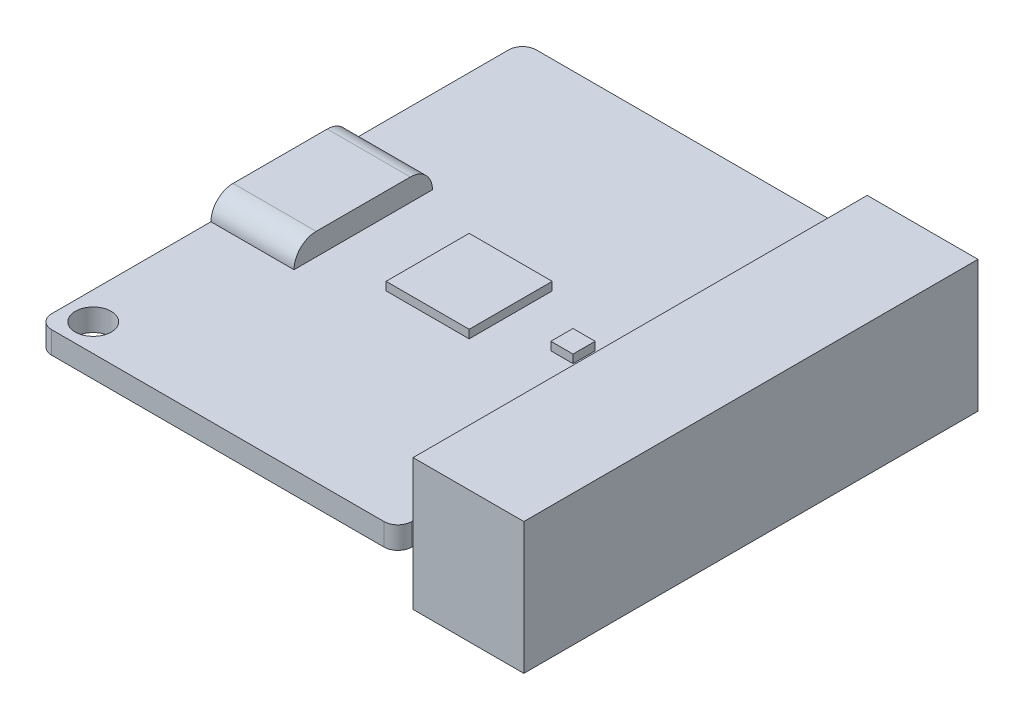
from build123d import *

# Parameters (mm, degrees)
SKETCH_1_R      = 1.3
EXTRUDE_1_DEPTH = 1.6
EXTRUDE_2_DEPTH = 6
SKETCH_3_W      = 6
SKETCH_3_H      = 6
EXTRUDE_3_DEPTH = 0.6
SKETCH_4_W      = 1.6
SKETCH_4_H      = 1.6
EXTRUDE_4_DEPTH = 0.6
SKETCH_5_W      = 32.8
SKETCH_5_H      = 9.5
EXTRUDE_5_DEPTH = 8


with BuildPart() as part:
    # 草图1 → 凸台-拉伸1 (new body)
    with BuildSketch(Plane(origin=(0, 0, 0), x_dir=(1, 0, 0), z_dir=(0, 1, 0))):
        with BuildLine():
            Line((-12, -17.5), (12, -17.5))
            ThreePointArc((12, -17.5), (12.707106781, -17.207106781), (13, -16.5))
            Line((13, -16.5), (13, 16.5))
            ThreePointArc((13, 16.5), (12.707106781, 17.207106781), (12, 17.5))
            Line((12, 17.5), (-12, 17.5))
            ThreePointArc((-12, 17.5), (-12.707106781, 17.207106781), (-13, 16.5))
            Line((-13, 16.5), (-13, -16.5))
            ThreePointArc((-13, -16.5), (-12.707106781, -17.207106781), (-12, -17.5))
        make_face()
        with Locations((-11, -15.5)):
            Circle(SKETCH_1_R, mode=Mode.SUBTRACT)
        with Locations((11, 15.5)):
            Circle(SKETCH_1_R, mode=Mode.SUBTRACT)
    extrude(amount=EXTRUDE_1_DEPTH)

    # 草图2 → 凸台-拉伸2 (add)
    with BuildSketch(Plane.ZY.offset(13)):
        with BuildLine():
            Line((-3.4, 3.2), (3.4, 3.2))
            ThreePointArc((3.4, 3.2), (5, 1.6), (3.4, 0))
            Line((3.4, 0), (-3.4, 0))
            ThreePointArc((-3.4, 0), (-5, 1.6), (-3.4, 3.2))
        make_face()
    extrude(amount=-EXTRUDE_2_DEPTH)

    # 草图3 → 凸台-拉伸3 (add)
    with BuildSketch(Plane(origin=(0, 1.6, 0), x_dir=(1, 0, 0), z_dir=(0, 1, 0))):
        with Locations((0.65, 0)):
            Rectangle(SKETCH_3_W, SKETCH_3_H)
    extrude(amount=EXTRUDE_3_DEPTH)

    # 草图4 → 凸台-拉伸4 (add)
    with BuildSketch(Plane(origin=(0, 1.6, 0), x_dir=(1, 0, 0), z_dir=(0, 1, 0))):
        with Locations((8.15, 0)):
            Rectangle(SKETCH_4_W, SKETCH_4_H)
    extrude(amount=EXTRUDE_4_DEPTH)

    # 草图5 → 凸台-拉伸5 (add)
    with BuildSketch(Plane(origin=(13, 0, 0), x_dir=(0, 0, -1), z_dir=(1, 0, 0))):
        with Locations((0, 0.8)):
            Rectangle(SKETCH_5_W, SKETCH_5_H)
    extrude(amount=EXTRUDE_5_DEPTH)


solid = part.part
